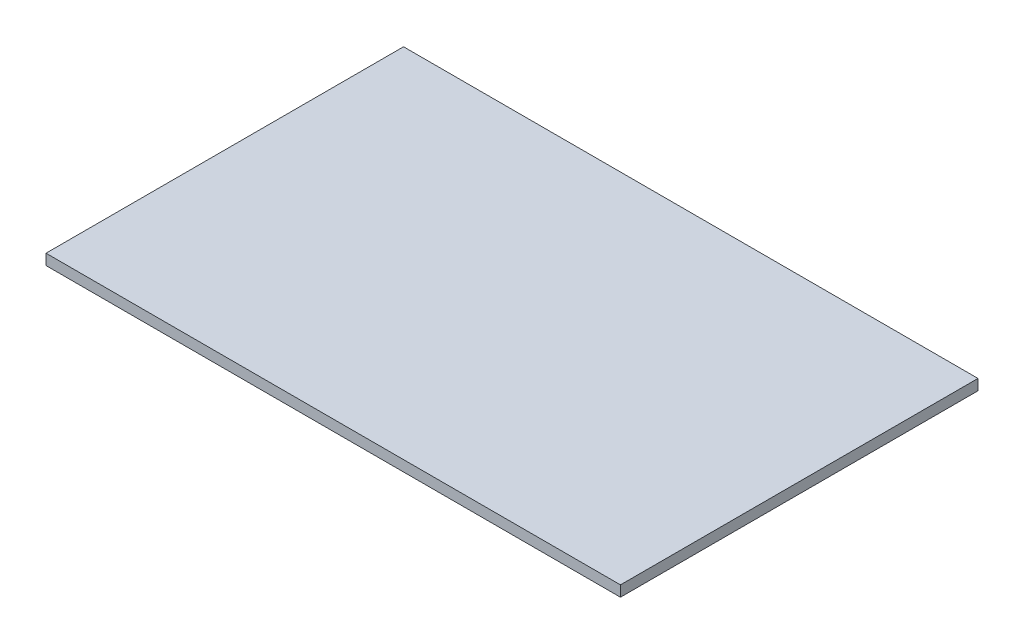
from build123d import *

# Parameters (mm, degrees)
SKETCH_1_W      = 964
SKETCH_1_H      = 600
EXTRUDE_1_DEPTH = 18


with BuildPart() as part:
    # Эскиз1 → Бобышка-Вытянуть1 (new body)
    with BuildSketch(Plane(origin=(0, 0, 0), x_dir=(1, 0, 0), z_dir=(0, 1, 0))):
        with Locations((482, 300)):
            Rectangle(SKETCH_1_W, SKETCH_1_H)
    extrude(amount=EXTRUDE_1_DEPTH)


solid = part.part
